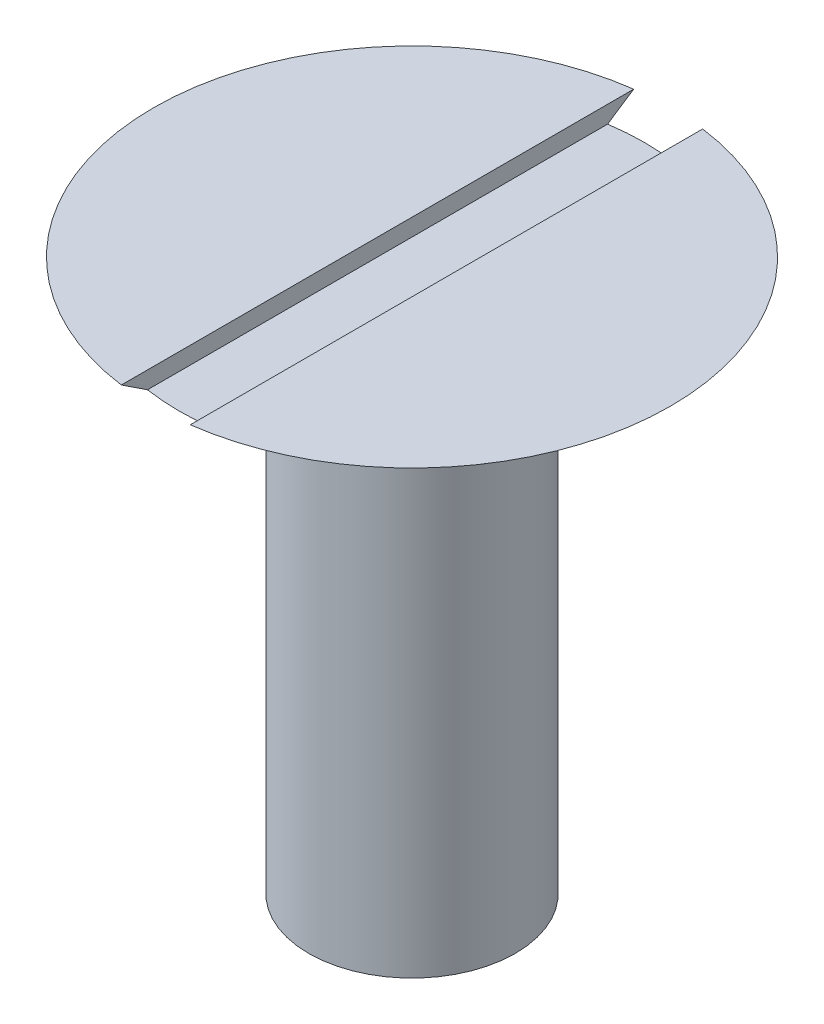
from build123d import *

# Parameters (mm, degrees)
SKETCH2_W               = 2
SKETCH2_H               = 1
CUT_EXTRUDE1_DEPTH      = 8.5
CUT_EXTRUDE1_DEPTH_BACK = 8.5


with BuildPart() as part:
    # Sketch1 → Revolve1 (revolve)
    with BuildSketch(Plane.XY):
        Polygon((0, 0), (3, 1.732050808), (3, 14.732050808), (7.5, 17.732050808), (0, 17.732050808), align=None)
    revolve(axis=Axis((0, 17.732050808, 0), (0, -1, 0)))

    # Sketch2 → Cut-Extrude1 (cut, two sides)
    with BuildSketch(Plane.XY) as cut_extrude1_sk:
        with Locations((0, 17.732050808)):
            Rectangle(SKETCH2_W, SKETCH2_H)
    extrude(amount=CUT_EXTRUDE1_DEPTH, mode=Mode.SUBTRACT)
    extrude(cut_extrude1_sk.sketch, amount=-CUT_EXTRUDE1_DEPTH_BACK, mode=Mode.SUBTRACT)


solid = part.part
